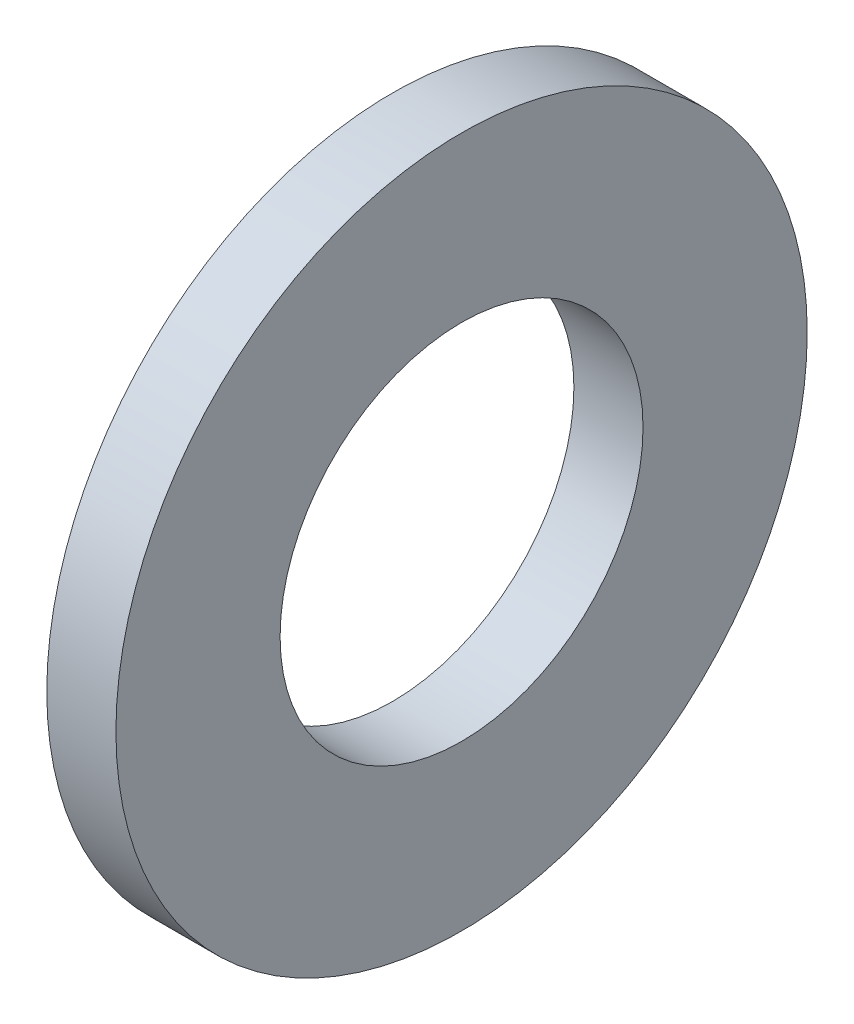
from build123d import *

# Parameters (mm, degrees)
SKETCH1_W = 2
SKETCH1_H = 4.75


with BuildPart() as part:
    # Sketch1 → Base-Revolve (revolve)
    with BuildSketch(Plane.XY):
        with Locations((-1, 7.625)):
            Rectangle(SKETCH1_W, SKETCH1_H)
    revolve(axis=Axis((-34.925, 0, 0), (1, 0, 0)))


solid = part.part
